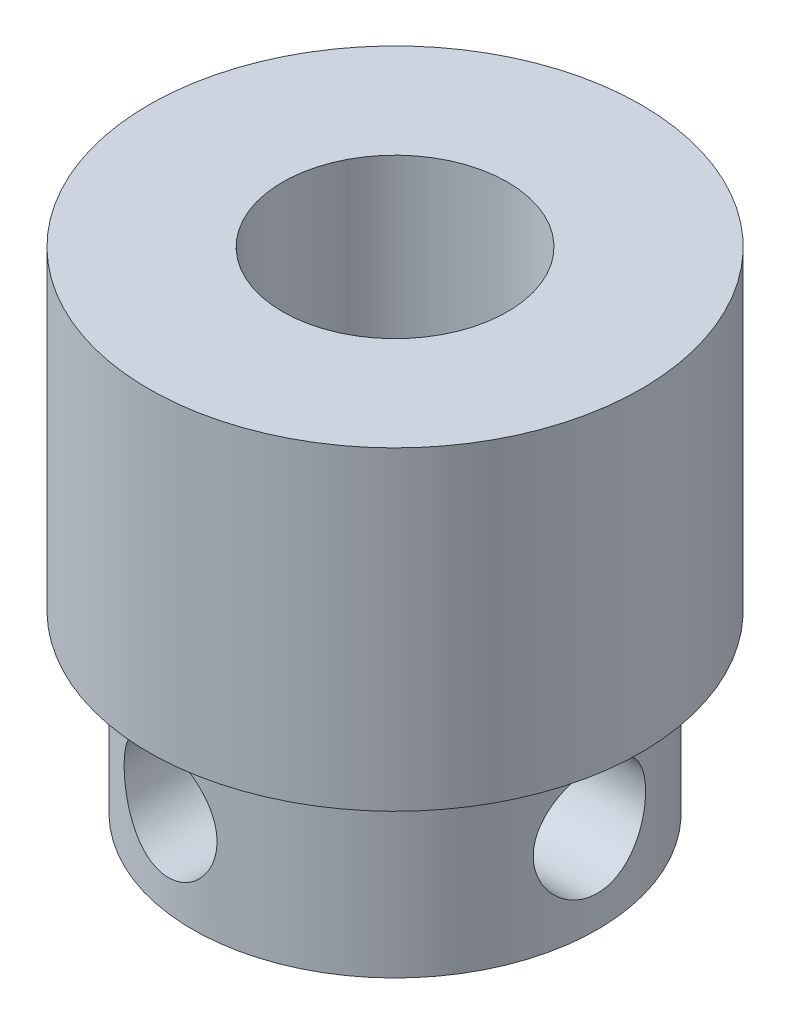
from build123d import *

# Parameters (mm, degrees)
SKETCH1_W                      = 5.475
SKETCH1_H                      = 7
SKETCH2_R                      = 4.5
BOSS_EXTRUDE1_DEPTH            = 3.9
F_5_0_5_DIAMETER_HOLE1_D       = 5
F_5_0_5_DIAMETER_HOLE1_DEPTH   = 10.9
F_2_5_2_5_DIAMETER_HOLE1_D     = 2.5
F_2_5_2_5_DIAMETER_HOLE1_DEPTH = 3.309936491
SKETCH7_W                      = 1.25
SKETCH7_H                      = 3.960443852


with BuildPart() as part:
    # Sketch1 → Revolve1 (revolve)
    with BuildSketch(Plane.XY.offset(-56.4)):
        with Locations((78.2375, 52.926431985)):
            Rectangle(SKETCH1_W, SKETCH1_H)
    revolve(axis=Axis((75.5, 56.426431985, -56.4), (0, -1, 0)))

    # Sketch2 → Boss-Extrude1 (add)
    with BuildSketch(Plane.XZ.offset(-49.426431985)):
        with Locations((75.5, -56.4)):
            Circle(SKETCH2_R)
    extrude(amount=BOSS_EXTRUDE1_DEPTH)

    # Ø5.0 (5) Diameter Hole1
    with Locations(Plane(origin=(0, 56.426431985, 0), x_dir=(1, 0, 0), z_dir=(0, 1, 0))):
        with Locations((75.5, 56.4)):
            Hole(F_5_0_5_DIAMETER_HOLE1_D / 2, depth=F_5_0_5_DIAMETER_HOLE1_DEPTH)

    # Ø2.5 (2.5) Diameter Hole1
    with Locations(Plane.ZY.offset(-77.665063509)):
        with Locations((-56.4, 47.476431985)):
            Hole(F_2_5_2_5_DIAMETER_HOLE1_D / 2, depth=F_2_5_2_5_DIAMETER_HOLE1_DEPTH)

    # Sketch7 → Ø2.5 (2.5) Diameter Hole2 (revolve, cut)
    with BuildSketch(Plane(origin=(74.761000333, 47.459423849, -54.885443852), x_dir=(0, 1, 0), z_dir=(1, 0, 0))):
        with Locations((0.625, 1.980221926)):
            Rectangle(SKETCH7_W, SKETCH7_H)
    revolve(axis=Axis((74.761000333, 47.459423849, -61.235443852), (0, 0, 1)), mode=Mode.SUBTRACT)


solid = part.part
